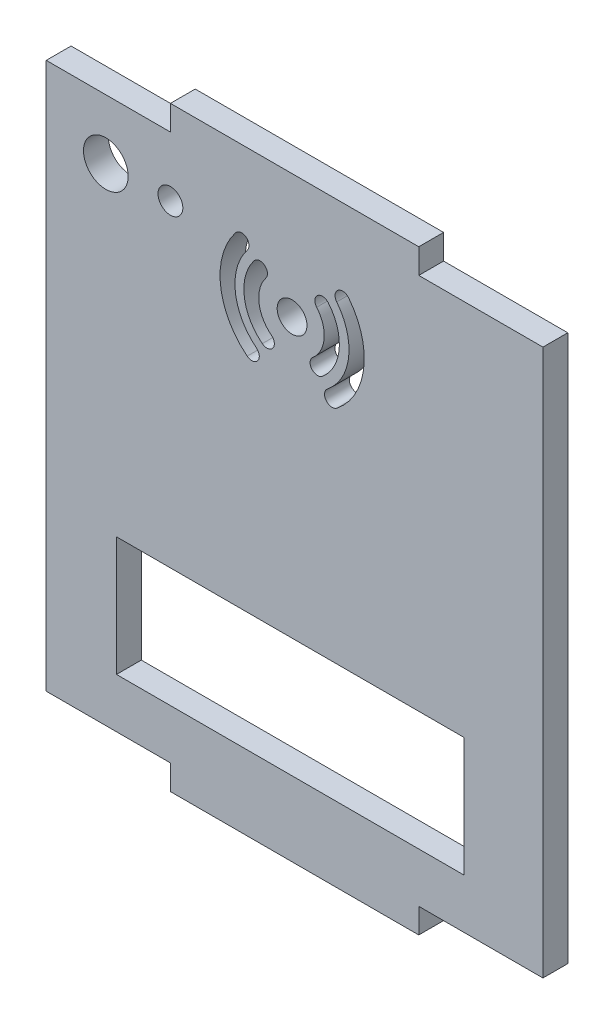
from build123d import *

# Parameters (mm, degrees)
SKETCH1_R           = 4.5
SKETCH1_R_2         = 3
SKETCH1_R_3         = 2.5
SKETCH1_W           = 70
SKETCH1_H           = 24
BOSS_EXTRUDE1_DEPTH = 5


with BuildPart() as part:
    # Sketch1 → Boss-Extrude1 (new body)
    with BuildSketch(Plane.XY):
        Polygon((-24.143882276, 60), (25.856117724, 60), (25.856117724, 55), (50.856117724, 55), (50.856117724, -55), (25.856117724, -55), (25.856117724, -60), (-24.143882276, -60), (-24.143882276, -55), (-49.143882276, -55), (-49.143882276, 55), (-24.143882276, 55), align=None)
        with Locations((-37.143882276, 43)):
            Circle(SKETCH1_R, mode=Mode.SUBTRACT)
        with Locations((0.348837209, 35)):
            Circle(SKETCH1_R_2, mode=Mode.SUBTRACT)
        with Locations((-24.143882276, 43)):
            Circle(SKETCH1_R_3, mode=Mode.SUBTRACT)
        with Locations((0, -33)):
            Rectangle(SKETCH1_W, SKETCH1_H, mode=Mode.SUBTRACT)
        with BuildLine():
            ThreePointArc((6.483996619, 27.71689355), (9.83698399, 34.188278863), (7.631943659, 41.13515941))
            ThreePointArc((7.631943659, 41.13515941), (5.486209752, 41.318729247), (5.302639914, 39.17299534))
            ThreePointArc((5.302639914, 39.17299534), (6.802457997, 34.447885818), (4.521832549, 30.046197295))
            ThreePointArc((4.521832549, 30.046197295), (4.338262711, 27.900463388), (6.483996619, 27.71689355))
        make_face(mode=Mode.SUBTRACT)
        with BuildLine():
            ThreePointArc((-7.289461523, 40.990419638), (-9.288121969, 33.834773518), (-5.641582428, 27.361701268))
            ThreePointArc((-5.641582428, 27.361701268), (-3.535600715, 27.61634027), (-3.790239716, 29.722321983))
            ThreePointArc((-3.790239716, 29.722321983), (-6.309814067, 34.194887447), (-4.928840807, 39.139076925))
            ThreePointArc((-4.928840807, 39.139076925), (-5.183479809, 41.245058639), (-7.289461523, 40.990419638))
        make_face(mode=Mode.SUBTRACT)
        with BuildLine():
            ThreePointArc((-10.994860864, 44.031639609), (-14.058702235, 33.365127781), (-8.6828024, 23.656301927))
            ThreePointArc((-8.6828024, 23.656301927), (-6.575008846, 23.895480389), (-6.814187308, 26.003273942))
            ThreePointArc((-6.814187308, 26.003273942), (-11.077832005, 33.703377206), (-8.647888849, 42.163024517))
            ThreePointArc((-8.647888849, 42.163024517), (-8.887067311, 44.270818071), (-10.994860864, 44.031639609))
        make_face(mode=Mode.SUBTRACT)
        with BuildLine():
            ThreePointArc((9.373364684, 23.607418094), (14.785913704, 33.325532654), (11.741419115, 44.024527475))
            ThreePointArc((11.741419115, 44.024527475), (9.586661553, 44.274444498), (9.33674453, 42.119686935))
            ThreePointArc((9.33674453, 42.119686935), (11.738626336, 33.678968697), (7.468524145, 26.01209268))
            ThreePointArc((7.468524145, 26.01209268), (7.218607122, 23.857335117), (9.373364684, 23.607418094))
        make_face(mode=Mode.SUBTRACT)
    extrude(amount=BOSS_EXTRUDE1_DEPTH)


solid = part.part
